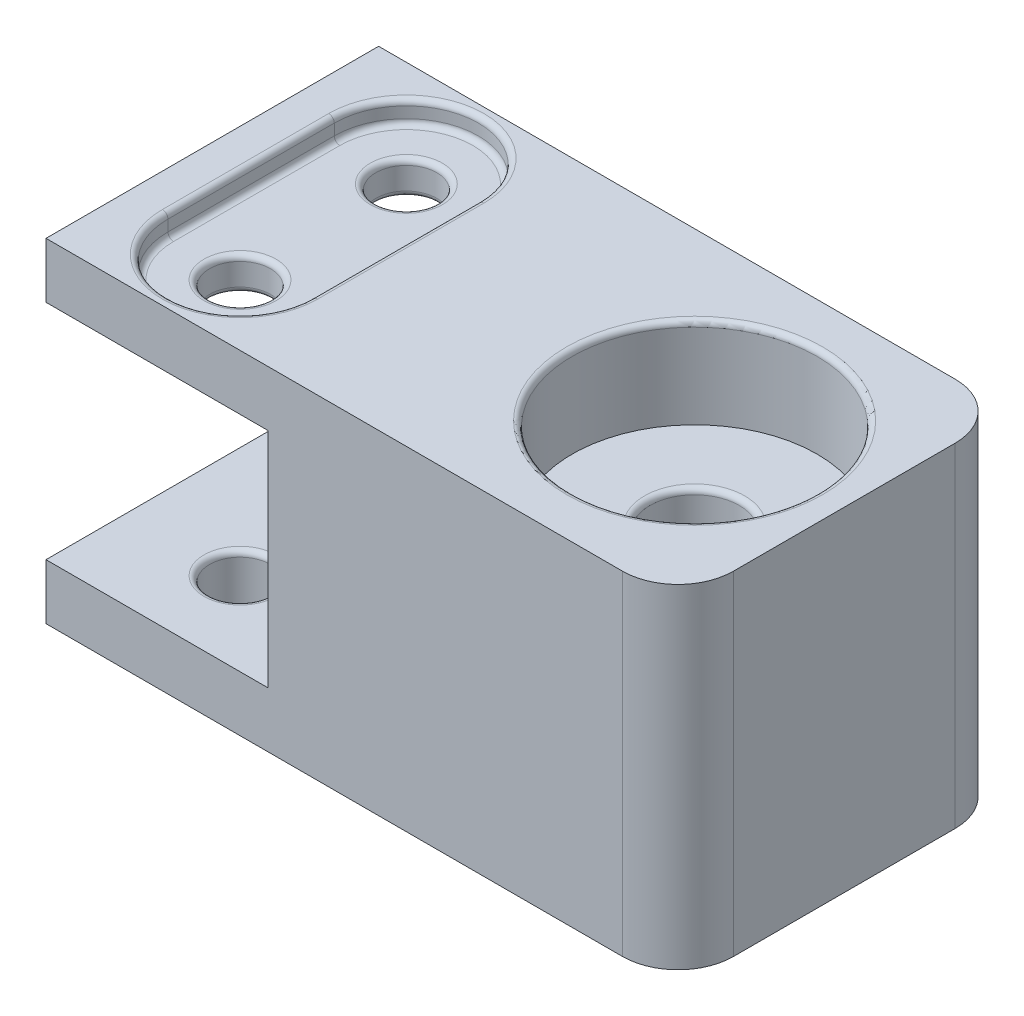
from build123d import *

# Parameters (mm, degrees)
SKETCH4_W           = 57
SKETCH4_H           = 30
BOSS_EXTRUDE2_DEPTH = 5
SKETCH5_W           = 37
SKETCH5_H           = 30
BOSS_EXTRUDE3_DEPTH = 20.1
BOSS_EXTRUDE4_DEPTH = 5
SKETCH7_R           = 2.75
CUT_EXTRUDE3_DEPTH  = 31.1
FILLET5_R           = 0.5
SKETCH8_R           = 11.049
CUT_EXTRUDE4_DEPTH  = 8.128
FILLET6_R           = 5
SKETCH11_R          = 11.049
CUT_EXTRUDE5_DEPTH  = 8.128
SKETCH12_R          = 4.025
CUT_EXTRUDE6_DEPTH  = 22.972
FILLET7_R           = 0.5
CUT_EXTRUDE7_DEPTH  = 2
FILLET8_R           = 0.5


with BuildPart() as part:
    # Sketch4 → Boss-Extrude2 (new body)
    with BuildSketch(Plane(origin=(0, 0, 0), x_dir=(1, 0, 0), z_dir=(0, 1, 0))):
        Rectangle(SKETCH4_W, SKETCH4_H)
    extrude(amount=BOSS_EXTRUDE2_DEPTH)

    # Sketch5 → Boss-Extrude3 (add)
    with BuildSketch(Plane(origin=(0, 5, 0), x_dir=(1, 0, 0), z_dir=(0, 1, 0))):
        with Locations((10, 0)):
            Rectangle(SKETCH5_W, SKETCH5_H)
    extrude(amount=BOSS_EXTRUDE3_DEPTH)

    # Sketch6 → Boss-Extrude4 (add)
    with BuildSketch(Plane(origin=(0, 25.1, 0), x_dir=(1, 0, 0), z_dir=(0, 1, 0))):
        Polygon((28.5, -15), (28.5, 15), (-8.5, 15), (-28.5, 15), (-28.5, -15), (-8.5, -15), align=None)
    extrude(amount=BOSS_EXTRUDE4_DEPTH)

    # Sketch7 → Cut-Extrude3 (cut, through all)
    with BuildSketch(Plane(origin=(0, 30.1, 0), x_dir=(1, 0, 0), z_dir=(0, 1, 0))):
        with Locations((-18.5, -7.5)):
            Circle(SKETCH7_R)
        with Locations((-18.5, 7.5)):
            Circle(SKETCH7_R)
    extrude(amount=-CUT_EXTRUDE3_DEPTH, mode=Mode.SUBTRACT)

    # Fillet5
    fillet5_edges = [part.edges().sort_by_distance(p)[0] for p in [
        (-21.25, 0, 7.5),
        (-21.25, 5, 7.5),
        (-21.25, 25.1, 7.5),
        (-21.25, 30.1, 7.5),
        (-21.25, 0, -7.5),
        (-21.25, 5, -7.5),
        (-21.25, 25.1, -7.5),
        (-21.25, 30.1, -7.5),
    ]]
    fillet(fillet5_edges, radius=FILLET5_R)

    # Sketch8 → Cut-Extrude4 (cut)
    with BuildSketch(Plane(origin=(0, 30.1, 0), x_dir=(1, 0, 0), z_dir=(0, 1, 0))):
        with Locations((15, 0)):
            Circle(SKETCH8_R)
    extrude(amount=-CUT_EXTRUDE4_DEPTH, mode=Mode.SUBTRACT)

    # Fillet6
    fillet6_edges = [part.edges().sort_by_distance(p)[0] for p in [
        (28.5, 15.05, 15),
        (28.5, 15.05, -15),
    ]]
    fillet(fillet6_edges, radius=FILLET6_R)

    # Sketch11 → Cut-Extrude5 (cut)
    with BuildSketch(Plane.XZ):
        with Locations((15, 0)):
            Circle(SKETCH11_R)
    extrude(amount=-CUT_EXTRUDE5_DEPTH, mode=Mode.SUBTRACT)

    # Sketch12 → Cut-Extrude6 (cut, through all)
    with BuildSketch(Plane.XZ.offset(-8.128)):
        with Locations((15, 0)):
            Circle(SKETCH12_R)
    extrude(amount=-CUT_EXTRUDE6_DEPTH, mode=Mode.SUBTRACT)

    # Fillet7
    fillet7_edges = [part.edges().sort_by_distance(p)[0] for p in [
        (3.951, 0, 0),
        (10.975, 21.972, 0),
        (10.975, 8.128, 0),
        (3.951, 30.1, 0),
    ]]
    fillet(fillet7_edges, radius=FILLET7_R)

    # Sketch13 → Cut-Extrude7 (cut)
    with BuildSketch(Plane(origin=(0, 30.1, 0), x_dir=(1, 0, 0), z_dir=(0, 1, 0))):
        with BuildLine():
            Line((-25, -7.5), (-25, 7.5))
            ThreePointArc((-25, 7.5), (-18.5, 14), (-12, 7.5))
            Line((-12, 7.5), (-12, -7.5))
            ThreePointArc((-12, -7.5), (-18.5, -14), (-25, -7.5))
        make_face()
    extrude(amount=-CUT_EXTRUDE7_DEPTH, mode=Mode.SUBTRACT)

    # Fillet8
    fillet8_edges = [part.edges().sort_by_distance(p)[0] for p in [
        (-21.25, 28.1, -7.5),
        (-18.5, 30.1, -14),
        (-25, 30.1, 0),
        (-18.5, 30.1, 14),
        (-12, 30.1, 0),
        (-18.5, 28.1, -14),
        (-12, 28.1, 0),
        (-18.5, 28.1, 14),
        (-25, 28.1, 0),
        (-21.25, 28.1, 7.5),
    ]]
    fillet(fillet8_edges, radius=FILLET8_R)


solid = part.part
